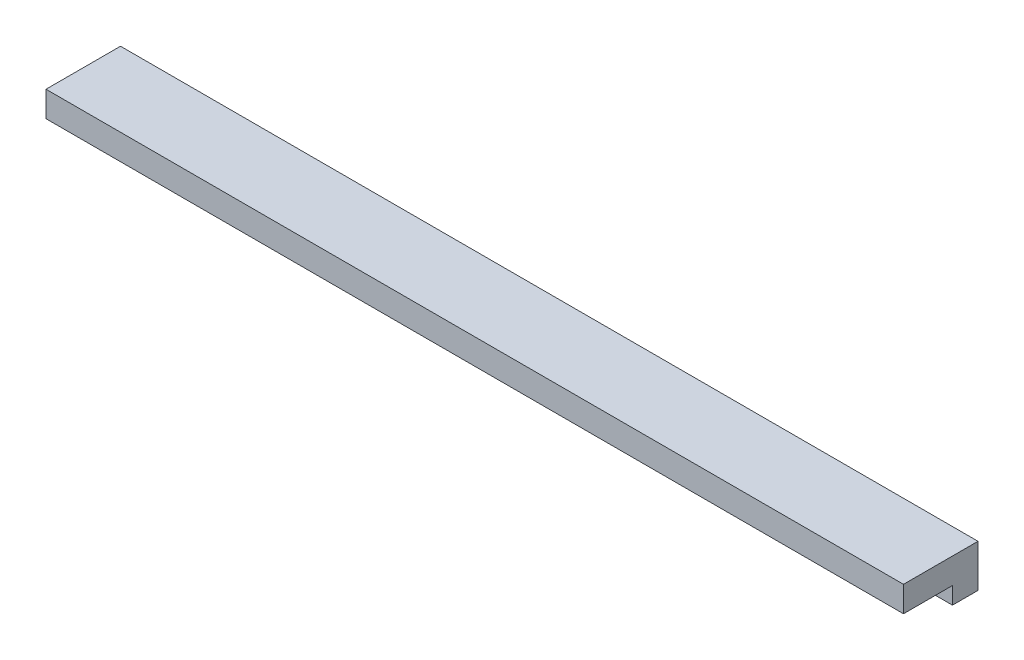
from build123d import *

# Parameters (mm, degrees)
EXTRUDE_1_DEPTH = 100.70048


with BuildPart() as part:
    # 草图2 → 凸台-拉伸1 (new body)
    with BuildSketch(Plane.ZY.offset(123.049709027)):
        Polygon((0, -3.703400415), (0, -8.703400415), (3, -8.703400415), (3, -6.703400415), (8.75, -6.703400415), (8.75, -3.703400415), align=None)
    extrude(amount=-EXTRUDE_1_DEPTH)


solid = part.part
